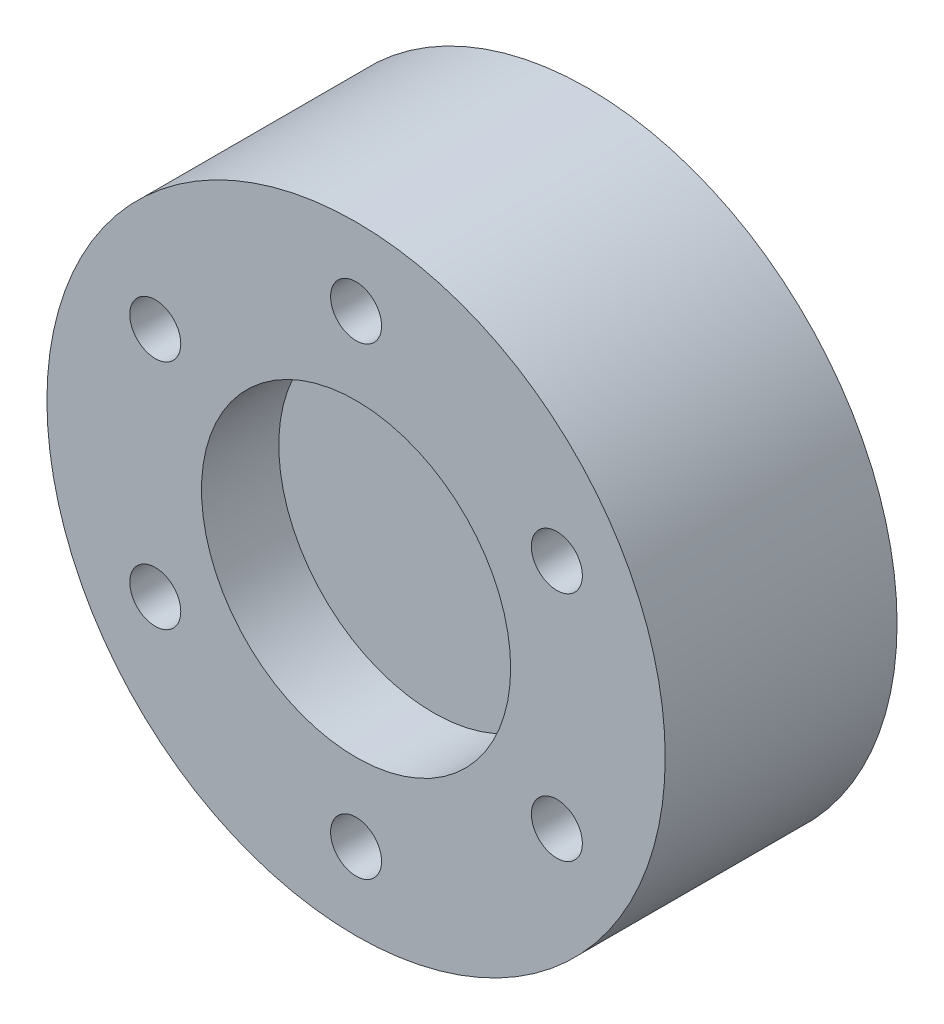
from build123d import *

# Parameters (mm, degrees)
SKETCH1_R           = 20
BOSS_EXTRUDE1_DEPTH = 15
SKETCH2_R           = 10
CUT_EXTRUDE1_DEPTH  = 5
CIRPATTERN2_COUNT   = 6
SKETCH5_R           = 17.5
CUT_EXTRUDE2_DEPTH  = 3


with BuildPart() as part:
    # Sketch1 → Boss-Extrude1 (new body)
    with BuildSketch(Plane.XY):
        Circle(SKETCH1_R)
    extrude(amount=BOSS_EXTRUDE1_DEPTH)

    # Sketch2 → Cut-Extrude1 (cut)
    with BuildSketch(Plane.XY.offset(15)):
        Circle(SKETCH2_R)
    extrude(amount=-CUT_EXTRUDE1_DEPTH, mode=Mode.SUBTRACT)

    # Sketch4 → M4x0.7 Tapped Hole1 (revolve, cut)
    with BuildSketch(Plane(origin=(0, 15, 15), x_dir=(0, -1, 0), z_dir=(1, 0, 0))):
        Polygon((0, 0), (0, 8.091420021), (1.65, 7.1), (1.65, 0), align=None)
    m4x0_7_tapped_hole1 = revolve(axis=Axis((0, 15, 21.35), (0, 0, -1)), mode=Mode.SUBTRACT)

    # CirPattern2: M4x0.7 Tapped Hole1 ×6 about axis
    cirpattern2_axis = Axis((0, 0, 0), (0, 0, 1))
    for i in range(1, CIRPATTERN2_COUNT):
        add(m4x0_7_tapped_hole1.rotate(cirpattern2_axis, i * 360 / CIRPATTERN2_COUNT), mode=Mode.SUBTRACT)

    # Sketch5 → Cut-Extrude2 (cut)
    with BuildSketch(Plane(origin=(0, 0, 0), x_dir=(-1, 0, 0), z_dir=(0, 0, -1))):
        Circle(SKETCH5_R)
    extrude(amount=-CUT_EXTRUDE2_DEPTH, mode=Mode.SUBTRACT)


solid = part.part
